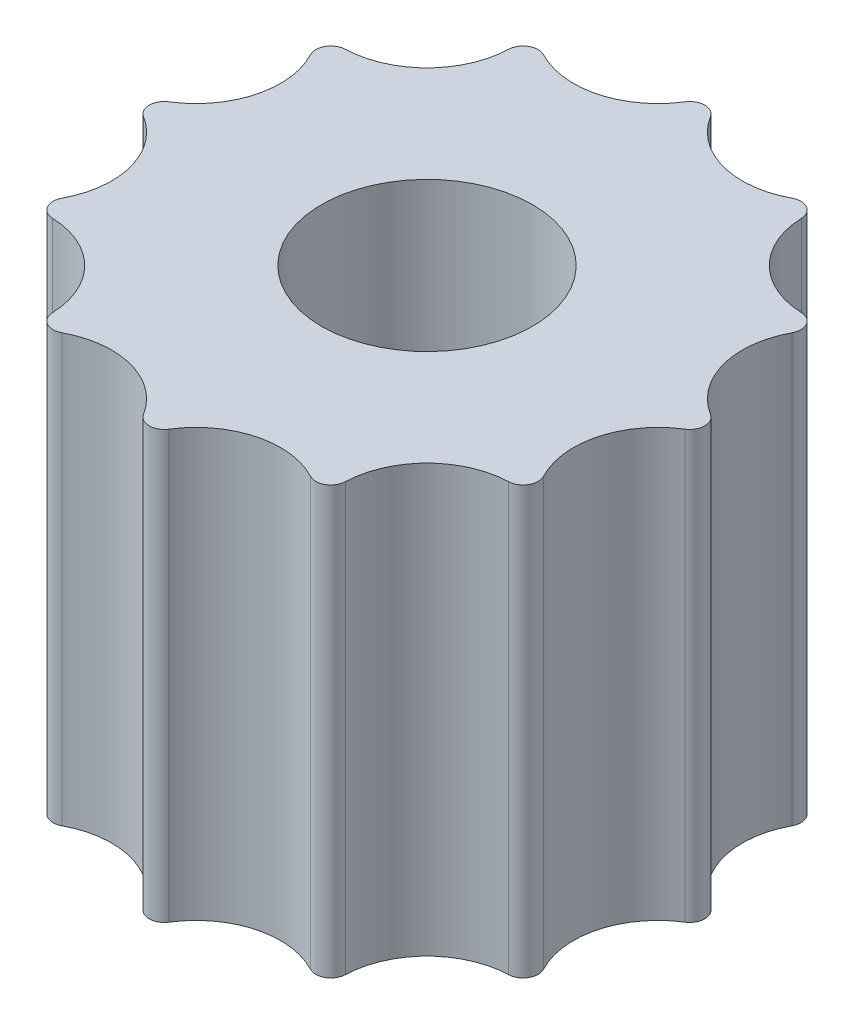
from build123d import *

# Parameters (mm, degrees)
SKETCH_1_R      = 2.1
EXTRUDE_1_DEPTH = 8.5
FILLET_1_R      = 0.3


with BuildPart() as part:
    # 草图1 → 凸台-拉伸1 (new body)
    with BuildSketch(Plane(origin=(0, 0, 0), x_dir=(1, 0, 0), z_dir=(0, 1, 0))):
        with BuildLine():
            ThreePointArc((-3.125, 5.412658774), (-1.246843801, 4.653284414), (0, 6.25))
            ThreePointArc((0, 6.25), (1.246843801, 4.653284414), (3.125, 5.412658774))
            ThreePointArc((3.125, 5.412658774), (3.406440613, 3.406440613), (5.412658774, 3.125))
            ThreePointArc((5.412658774, 3.125), (4.653284414, 1.246843801), (6.25, 0))
            ThreePointArc((6.25, 0), (4.653284414, -1.246843801), (5.412658774, -3.125))
            ThreePointArc((5.412658774, -3.125), (3.406440613, -3.406440613), (3.125, -5.412658774))
            ThreePointArc((3.125, -5.412658774), (1.246843801, -4.653284414), (0, -6.25))
            ThreePointArc((0, -6.25), (-1.246843801, -4.653284414), (-3.125, -5.412658774))
            ThreePointArc((-3.125, -5.412658774), (-3.406440613, -3.406440613), (-5.412658774, -3.125))
            ThreePointArc((-5.412658774, -3.125), (-4.653284414, -1.246843801), (-6.25, 0))
            ThreePointArc((-6.25, 0), (-4.653284414, 1.246843801), (-5.412658774, 3.125))
            ThreePointArc((-5.412658774, 3.125), (-3.406440613, 3.406440613), (-3.125, 5.412658774))
        make_face()
        Circle(SKETCH_1_R, mode=Mode.SUBTRACT)
    extrude(amount=EXTRUDE_1_DEPTH)

    # 圆角1
    fillet_1_edges = [part.edges().sort_by_distance(p)[0] for p in [
        (-3.125, 4.25, -5.412658774),
        (0, 4.25, -6.25),
        (3.125, 4.25, -5.412658774),
        (5.412658774, 4.25, -3.125),
        (6.25, 4.25, 0),
        (5.412658774, 4.25, 3.125),
        (3.125, 4.25, 5.412658774),
        (0, 4.25, 6.25),
        (-3.125, 4.25, 5.412658774),
        (-5.412658774, 4.25, 3.125),
        (-6.25, 4.25, 0),
        (-5.412658774, 4.25, -3.125),
    ]]
    fillet(fillet_1_edges, radius=FILLET_1_R)


solid = part.part
